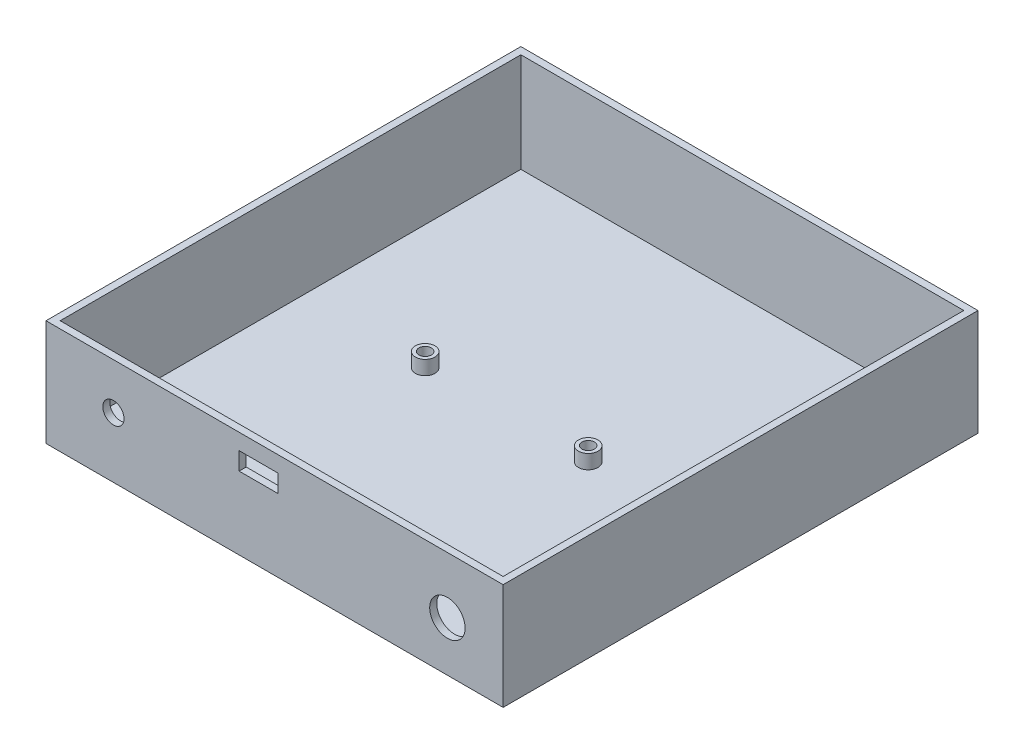
from build123d import *

# Parameters (mm, degrees)
SKETCH1_W           = 125
SKETCH1_H           = 130
BOSS_EXTRUDE1_DEPTH = 2
SKETCH2_W           = 129
SKETCH2_H           = 134
SKETCH2_W_2         = 125
SKETCH2_H_2         = 130
BOSS_EXTRUDE2_DEPTH = 30
SKETCH3_R           = 2.75
BOSS_EXTRUDE3_DEPTH = 4
SKETCH4_R           = 1.75
CUT_EXTRUDE1_DEPTH  = 4
SKETCH5_W           = 11
SKETCH5_H           = 2
CUT_EXTRUDE2_DEPTH  = 5
SKETCH6_R           = 3
SKETCH6_R_2         = 5
CUT_EXTRUDE3_DEPTH  = 5


with BuildPart() as part:
    # Sketch1 → Boss-Extrude1 (new body)
    with BuildSketch(Plane(origin=(0, 0, 0), x_dir=(1, 0, 0), z_dir=(0, 1, 0))):
        with Locations((62.5, 65)):
            Rectangle(SKETCH1_W, SKETCH1_H)
    extrude(amount=BOSS_EXTRUDE1_DEPTH)

    # Sketch2 → Boss-Extrude2 (add)
    with BuildSketch(Plane.XZ):
        with Locations((62.5, -65)):
            Rectangle(SKETCH2_W, SKETCH2_H)
        with Locations((62.5, -65)):
            Rectangle(SKETCH2_W_2, SKETCH2_H_2, mode=Mode.SUBTRACT)
    extrude(amount=-BOSS_EXTRUDE2_DEPTH)

    # Sketch3 → Boss-Extrude3 (add)
    with BuildSketch(Plane(origin=(0, 2, 0), x_dir=(1, 0, 0), z_dir=(0, 1, 0))):
        with Locations((35, 68)):
            Circle(SKETCH3_R)
        with Locations((81, 68)):
            Circle(SKETCH3_R)
        with Locations((81, 2)):
            Circle(SKETCH3_R)
        with Locations((35, 2)):
            Circle(SKETCH3_R)
    extrude(amount=BOSS_EXTRUDE3_DEPTH)

    # Sketch4 → Cut-Extrude1 (cut)
    with BuildSketch(Plane(origin=(0, 6, 0), x_dir=(1, 0, 0), z_dir=(0, 1, 0))):
        with Locations((81, 2)):
            Circle(SKETCH4_R)
        with Locations((35, 2)):
            Circle(SKETCH4_R)
        with Locations((35, 68)):
            Circle(SKETCH4_R)
        with Locations((81, 68)):
            Circle(SKETCH4_R)
    extrude(amount=-CUT_EXTRUDE1_DEPTH, mode=Mode.SUBTRACT)

    # Sketch5 → Cut-Extrude2 (cut)
    with BuildSketch(Plane(origin=(0, 20.5, 0), x_dir=(1, 0, 0), z_dir=(0, 1, 0))):
        with Locations((58, -1)):
            Rectangle(SKETCH5_W, SKETCH5_H)
    extrude(amount=CUT_EXTRUDE2_DEPTH, mode=Mode.SUBTRACT)

    # Sketch6 → Cut-Extrude3 (cut)
    with BuildSketch(Plane(origin=(0, 0, 0), x_dir=(-1, 0, 0), z_dir=(0, 0, -1))):
        with Locations((-17.024516763, 17.032581473)):
            Circle(SKETCH6_R)
        with Locations((-111.272952747, 14.032581473)):
            Circle(SKETCH6_R_2)
    extrude(amount=-CUT_EXTRUDE3_DEPTH, mode=Mode.SUBTRACT)


solid = part.part
